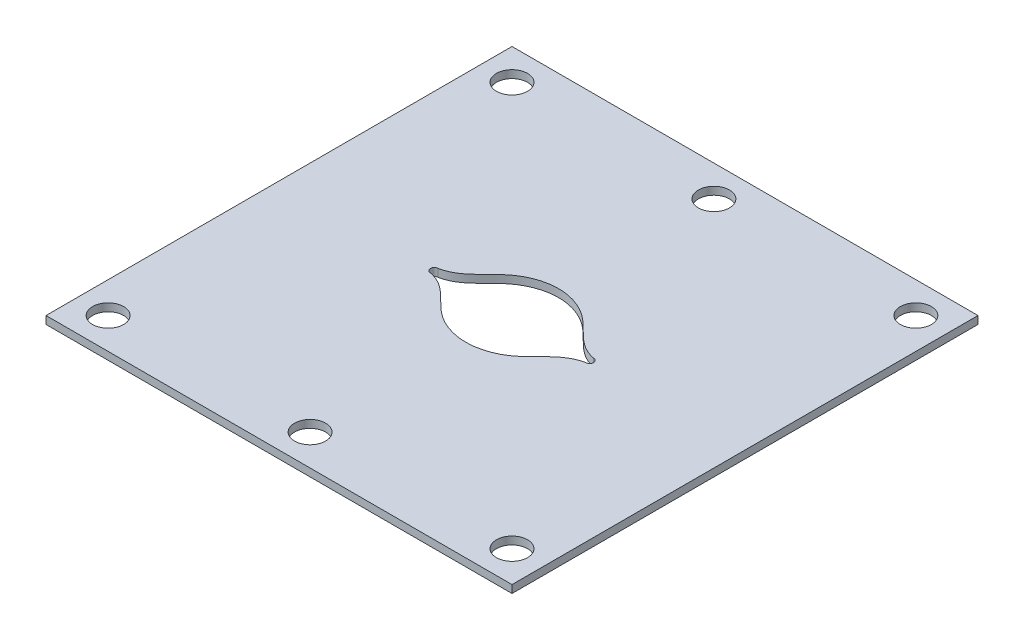
from build123d import *

# Parameters (mm, degrees)
SKETCH1_W           = 60
SKETCH1_H           = 60
BOSS_EXTRUDE1_DEPTH = 1
SKETCH2_R           = 2
CUT_EXTRUDE1_DEPTH  = 2
SKETCH3_R           = 0.5
CUT_EXTRUDE2_DEPTH  = 2
CUT_EXTRUDE3_DEPTH  = 10


with BuildPart() as part:
    # Sketch1 → Boss-Extrude1 (new body)
    with BuildSketch(Plane(origin=(0, 0, 0), x_dir=(1, 0, 0), z_dir=(0, 1, 0))):
        Rectangle(SKETCH1_W, SKETCH1_H)
    extrude(amount=BOSS_EXTRUDE1_DEPTH)

    # Sketch2 → Cut-Extrude1 (cut, through all)
    with BuildSketch(Plane(origin=(0, 1, 0), x_dir=(1, 0, 0), z_dir=(0, 1, 0))):
        with Locations((-26, 26)):
            Circle(SKETCH2_R)
        with Locations((0, 26)):
            Circle(SKETCH2_R)
        with Locations((26, 26)):
            Circle(SKETCH2_R)
        with Locations((26, -26)):
            Circle(SKETCH2_R)
        with Locations((0, -26)):
            Circle(SKETCH2_R)
        with Locations((-26, -26)):
            Circle(SKETCH2_R)
    extrude(amount=-CUT_EXTRUDE1_DEPTH, mode=Mode.SUBTRACT)

    # Sketch3 → Cut-Extrude2 (cut, through all)
    with BuildSketch(Plane(origin=(0, 1, 0), x_dir=(1, 0, 0), z_dir=(0, 1, 0))):
        with Locations((10, 0)):
            Circle(SKETCH3_R)
        with Locations((-10, 0)):
            Circle(SKETCH3_R)
    extrude(amount=-CUT_EXTRUDE2_DEPTH, mode=Mode.SUBTRACT)

    # Sketch7 → Cut-Extrude3 (cut)
    with BuildSketch(Plane(origin=(0, 1, 0), x_dir=(1, 0, 0), z_dir=(0, 1, 0))):
        with BuildLine():
            add(Edge.make_bspline(
                [(10, 0.5), (7.54185609, 0.971550622), (5.54199885, 4.633621193), (0, 6.558338078), (-5.54199885, 4.633621193), (-7.54185609, 0.971550622), (-10, 0.5)],
                knots=[0, 0, 0, 0, 0.295686937, 0.5, 0.704313063, 1, 1, 1, 1], degree=3))
            add(Edge.make_bspline(
                [(-10, 0.5), (-11, 0), (-10, -0.5)],
                knots=[0, 0, 0, 1, 1, 1], degree=2))
            add(Edge.make_bspline(
                [(10, -0.5), (7.539614158, -0.960866701), (5.551451154, -4.662870645), (0, -6.482717161), (-5.551451154, -4.662870645), (-7.539614158, -0.960866701), (-10, -0.5)],
                knots=[0, 0, 0, 0, 0.296041393, 0.5, 0.703958607, 1, 1, 1, 1], degree=3))
            add(Edge.make_bspline(
                [(10, 0.5), (11, 0), (10, -0.5)],
                knots=[0, 0, 0, 1, 1, 1], degree=2))
        make_face()
    extrude(amount=-CUT_EXTRUDE3_DEPTH, mode=Mode.SUBTRACT)


solid = part.part
